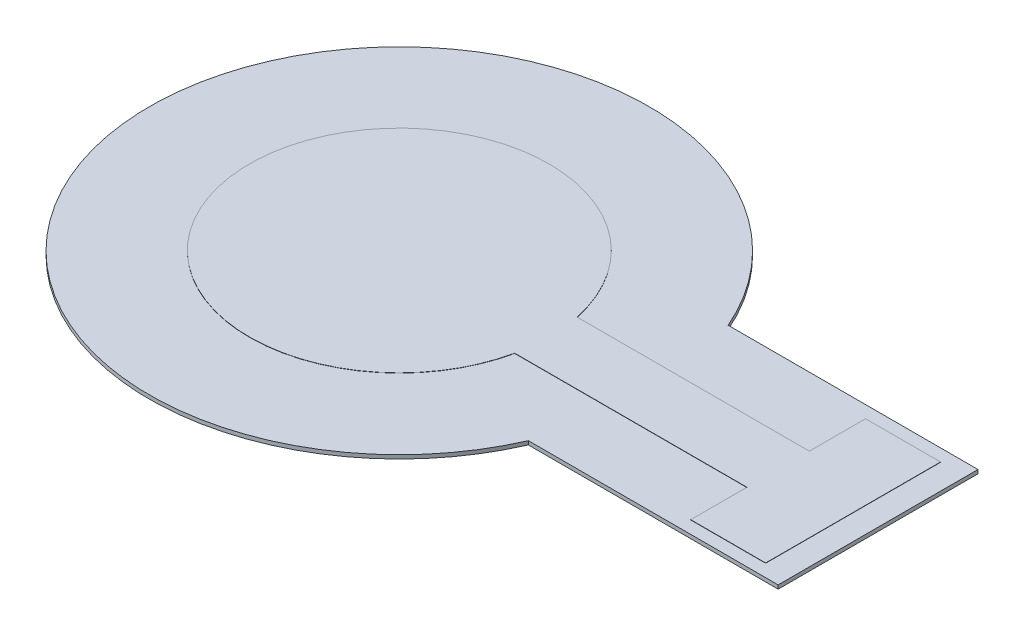
from build123d import *

# Parameters (mm, degrees)
BOSS_EXTRUDE1_DEPTH      = 0.15
BOSS_EXTRUDE2_DEPTH      = 0.01
BOSS_EXTRUDE2_DEPTH_BACK = 0.049


with BuildPart() as part:
    # Sketch1 → Boss-Extrude1 (new body)
    with BuildSketch(Plane(origin=(0, 0, 0), x_dir=(1, 0, 0), z_dir=(0, 1, 0))):
        with BuildLine():
            Line((37.726430303, 251.456293434), (27.726430303, 251.456293434))
            ThreePointArc((27.726430303, 251.456293434), (8.561278913, 247.456293434), (27.726430303, 243.456293434))
            Line((27.726430303, 243.456293434), (37.726430303, 243.456293434))
            Line((37.726430303, 243.456293434), (37.726430303, 251.456293434))
        make_face()
    extrude(amount=BOSS_EXTRUDE1_DEPTH)


with BuildPart() as body_2:
    # Sketch2 → Boss-Extrude2 (new body, two sides)
    with BuildSketch(Plane(origin=(0, 0.15, 0), x_dir=(1, 0, 0), z_dir=(0, 1, 0))) as boss_extrude2_sk:
        with BuildLine():
            Line((33.726430303, 248.706293434), (24.42962621, 248.706293434))
            ThreePointArc((24.42962621, 248.706293434), (12.561278913, 247.456293434), (24.42962621, 246.206293434))
            Line((24.42962621, 246.206293434), (33.726430303, 246.206293434))
            Line((33.726430303, 246.206293434), (33.726430303, 243.956293434))
            Line((33.726430303, 243.956293434), (36.726430303, 243.956293434))
            Line((36.726430303, 243.956293434), (36.726430303, 250.956293434))
            Line((36.726430303, 250.956293434), (33.726430303, 250.956293434))
            Line((33.726430303, 250.956293434), (33.726430303, 248.706293434))
        make_face()
    extrude(amount=BOSS_EXTRUDE2_DEPTH)
    extrude(boss_extrude2_sk.sketch, amount=-BOSS_EXTRUDE2_DEPTH_BACK)


solid = Compound([part.part, body_2.part])
